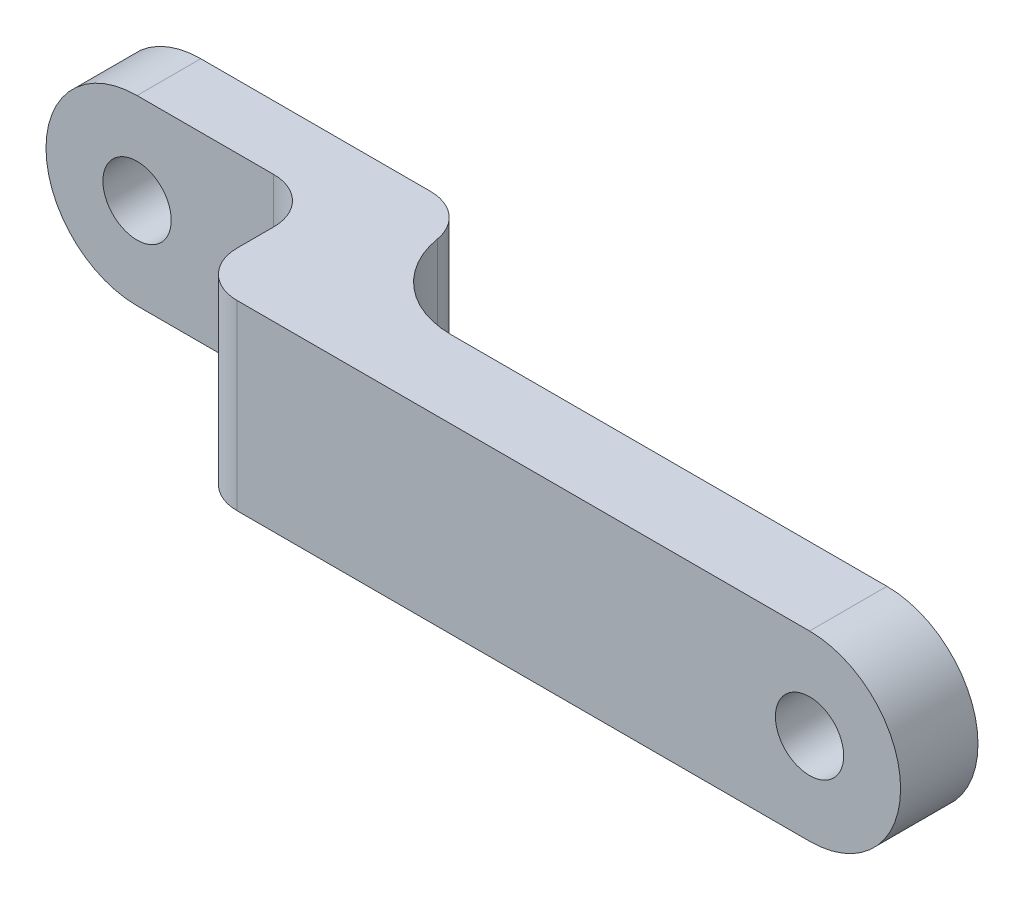
from build123d import *

# Parameters (mm, degrees)
SKETCH1_R           = 0.75
BOSS_EXTRUDE1_DEPTH = 0.85
SKETCH2_R           = 0.75
BOSS_EXTRUDE2_DEPTH = 2.5
SKETCH3_R           = 0.75
CUT_EXTRUDE1_DEPTH  = 2.8
FILLET1_R           = 2
FILLET2_R           = 1
FILLET3_R           = 1


with BuildPart() as part:
    # Sketch1 → Boss-Extrude1 (new body, symmetric)
    with BuildSketch(Plane.XY):
        with BuildLine():
            Line((0, 2), (17.57, 2))
            ThreePointArc((17.57, 2), (19.57, 0), (17.57, -2))
            Line((17.57, -2), (0, -2))
            ThreePointArc((0, -2), (-2, 0), (0, 2))
        make_face()
        Circle(SKETCH1_R, mode=Mode.SUBTRACT)
        with Locations((17.57, 0)):
            Circle(SKETCH1_R, mode=Mode.SUBTRACT)
    extrude(amount=BOSS_EXTRUDE1_DEPTH, both=True)

    # Sketch2 → Boss-Extrude2 (add)
    with BuildSketch(Plane(origin=(0, 0, -0.85), x_dir=(-1, 0, 0), z_dir=(0, 0, -1))):
        with BuildLine():
            Line((-6, 2), (-6, -2))
            Line((-6, -2), (0, -2))
            ThreePointArc((0, -2), (2, 0), (0, 2))
            Line((0, 2), (-6, 2))
        make_face()
        Circle(SKETCH2_R, mode=Mode.SUBTRACT)
    extrude(amount=BOSS_EXTRUDE2_DEPTH)

    # Sketch3 → Cut-Extrude1 (cut)
    with BuildSketch(Plane.XY.offset(0.85)):
        with BuildLine():
            Line((4, 2), (4, -2))
            Line((4, -2), (0, -2))
            ThreePointArc((0, -2), (-2, 0), (0, 2))
            Line((0, 2), (4, 2))
        make_face()
        Circle(SKETCH3_R, mode=Mode.SUBTRACT)
    extrude(amount=-CUT_EXTRUDE1_DEPTH, mode=Mode.SUBTRACT)

    # Fillet1
    fillet1_edges = [part.edges().sort_by_distance(p)[0] for p in [
        (6, 0, -0.85),
    ]]
    fillet(fillet1_edges, radius=FILLET1_R)

    # Fillet2
    fillet2_edges = [part.edges().sort_by_distance(p)[0] for p in [
        (6, 0, -3.35),
    ]]
    fillet(fillet2_edges, radius=FILLET2_R)

    # Fillet3
    fillet3_edges = [part.edges().sort_by_distance(p)[0] for p in [
        (4, 0, -1.95),
        (4, 0, 0.85),
    ]]
    fillet(fillet3_edges, radius=FILLET3_R)


solid = part.part
